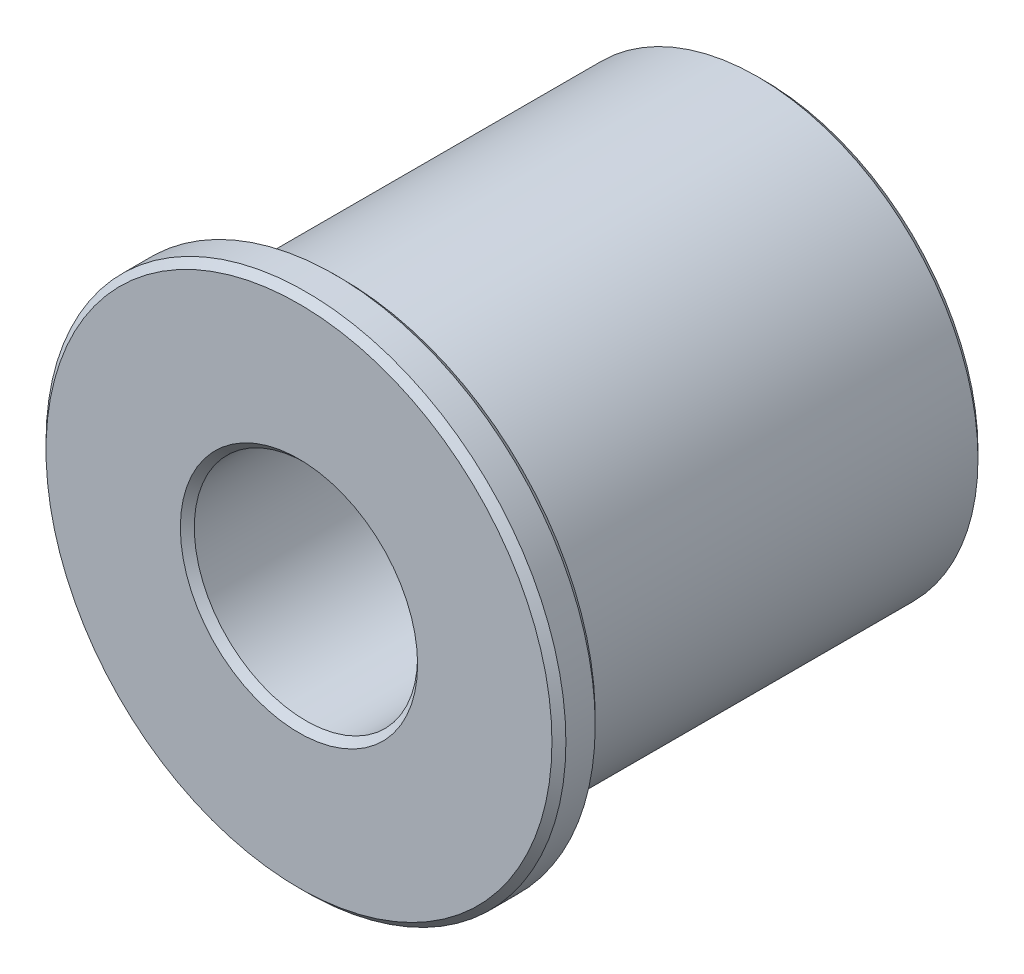
from build123d import *

# Parameters (mm, degrees)
CHAMFER1_SIZE = 0.254


with BuildPart() as part:
    # Sketch1 → Revolve1 (revolve)
    with BuildSketch(Plane(origin=(0, 0, 0), x_dir=(1, 0, 0), z_dir=(0, 1, 0))):
        Polygon((2.286, -10.6), (4.064, -10.6), (4.064, -16.9418), (9.4615, -16.9418), (9.4615, -15.367), (8.0264, -15.367), (8.0264, 0), (2.286, 0), align=None)
    revolve(axis=Axis((0, 0, 0), (0, 0, 1)))

    # Chamfer1
    chamfer1_edges = [part.edges().sort_by_distance(p)[0] for p in [
        (-2.286, 0, 0),
        (-8.0264, 0, 0),
        (-9.4615, 0, 15.367),
        (-9.4615, 0, 16.9418),
        (-4.064, 0, 16.9418),
        (-2.286, 0, 10.6),
    ]]
    chamfer(chamfer1_edges, length=CHAMFER1_SIZE)


solid = part.part
